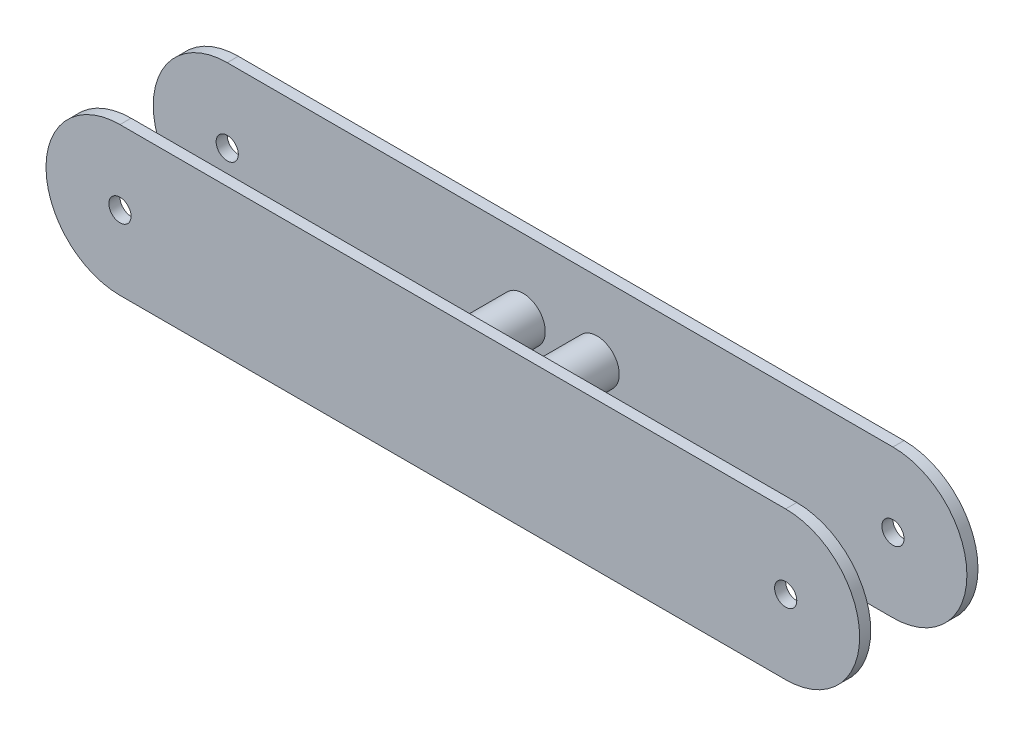
from build123d import *

# Parameters (mm, degrees)
SKETCH1_W           = 90
SKETCH1_H           = 20
BOSS_EXTRUDE2_DEPTH = 16
SKETCH2_R           = 1.5
CUT_EXTRUDE1_DEPTH  = 16
SKETCH3_W           = 110.03675272
SKETCH3_H           = 13
CUT_EXTRUDE2_DEPTH  = 23
SKETCH4_R           = 3
BOSS_EXTRUDE3_DEPTH = 16


with BuildPart() as part:
    # Sketch1 → Boss-Extrude2 (new body)
    with BuildSketch(Plane.XY):
        with BuildLine():
            Line((-3.745126611, 2.099543411), (-3.745126611, -17.900456589))
            ThreePointArc((-3.745126611, -17.900456589), (-13.745126611, -7.900456589), (-3.745126611, 2.099543411))
        make_face()
        with Locations((41.254873389, -7.900456589)):
            Rectangle(SKETCH1_W, SKETCH1_H)
        with BuildLine():
            ThreePointArc((86.254873389, 2.099543411), (96.254873389, -7.900456589), (86.254873389, -17.900456589))
            Line((86.254873389, -17.900456589), (86.254873389, 2.099543411))
        make_face()
    extrude(amount=BOSS_EXTRUDE2_DEPTH)

    # Sketch2 → Cut-Extrude1 (cut)
    with BuildSketch(Plane.XY.offset(16)):
        with Locations((-3.745126611, -7.900456589)):
            Circle(SKETCH2_R)
        with Locations((86.254873389, -7.900456589)):
            Circle(SKETCH2_R)
    extrude(amount=-CUT_EXTRUDE1_DEPTH, mode=Mode.SUBTRACT)

    # Sketch3 → Cut-Extrude2 (cut)
    with BuildSketch(Plane(origin=(0, 2.099543411, 0), x_dir=(1, 0, 0), z_dir=(0, 1, 0))):
        with Locations((41.257830101, -8)):
            Rectangle(SKETCH3_W, SKETCH3_H)
    extrude(amount=-CUT_EXTRUDE2_DEPTH, mode=Mode.SUBTRACT)

    # Sketch4 → Boss-Extrude3 (add)
    with BuildSketch(Plane(origin=(0, 0, 0), x_dir=(-1, 0, 0), z_dir=(0, 0, -1))):
        with Locations((-36.254873389, -7.900456589)):
            Circle(SKETCH4_R)
        with Locations((-46.254873389, -7.900456589)):
            Circle(SKETCH4_R)
    extrude(amount=-BOSS_EXTRUDE3_DEPTH)


solid = part.part
